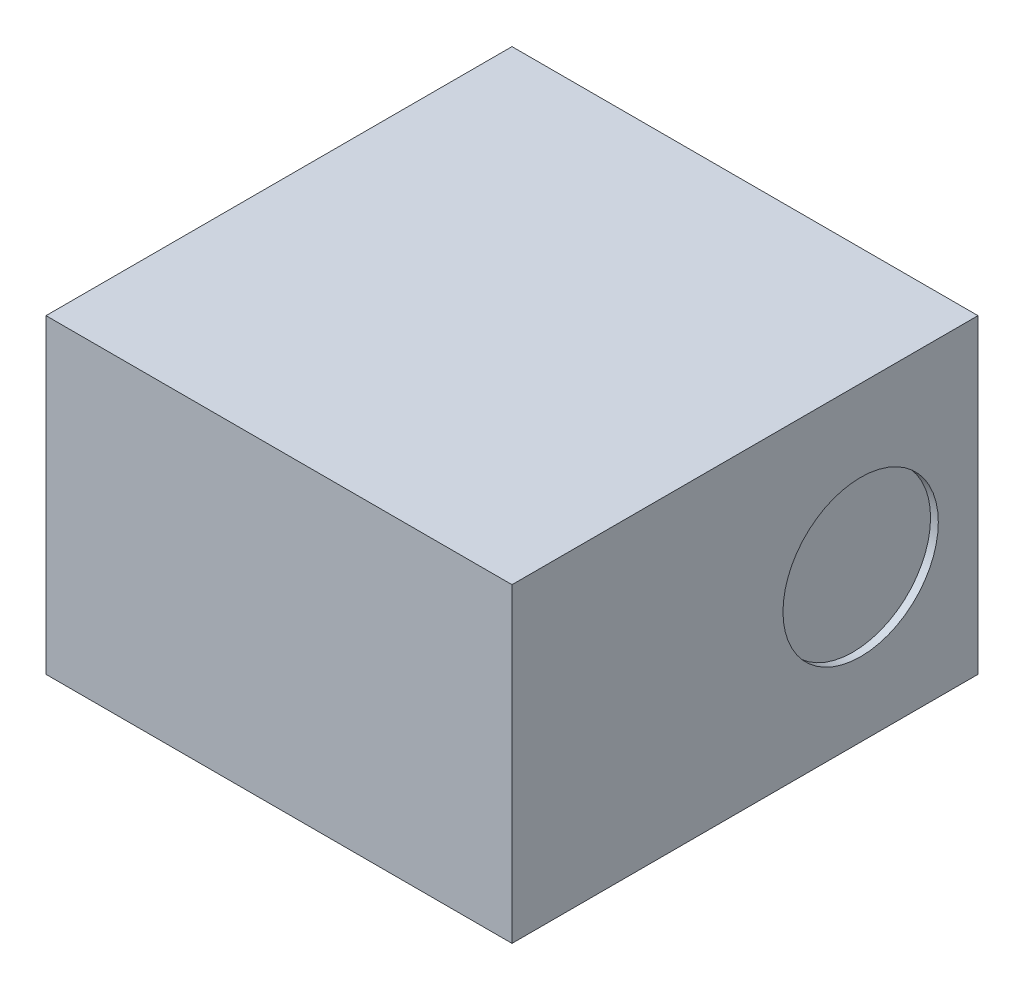
from build123d import *

# Parameters (mm, degrees)
SKETCH1_W           = 3
SKETCH1_H           = 3
BOSS_EXTRUDE1_DEPTH = 2
SKETCH2_R           = 0.5
CUT_EXTRUDE1_DEPTH  = 0.05


with BuildPart() as part:
    # Sketch1 → Boss-Extrude1 (new body)
    with BuildSketch(Plane(origin=(0, 0, 0), x_dir=(1, 0, 0), z_dir=(0, 1, 0))):
        Rectangle(SKETCH1_W, SKETCH1_H)
    extrude(amount=BOSS_EXTRUDE1_DEPTH)

    # Sketch2 → Cut-Extrude1 (cut)
    with BuildSketch(Plane(origin=(1.5, 0, 0), x_dir=(0, 0, -1), z_dir=(1, 0, 0))):
        with Locations((0.744511032, 0.976289458)):
            Circle(SKETCH2_R)
    extrude(amount=-CUT_EXTRUDE1_DEPTH, mode=Mode.SUBTRACT)


solid = part.part
